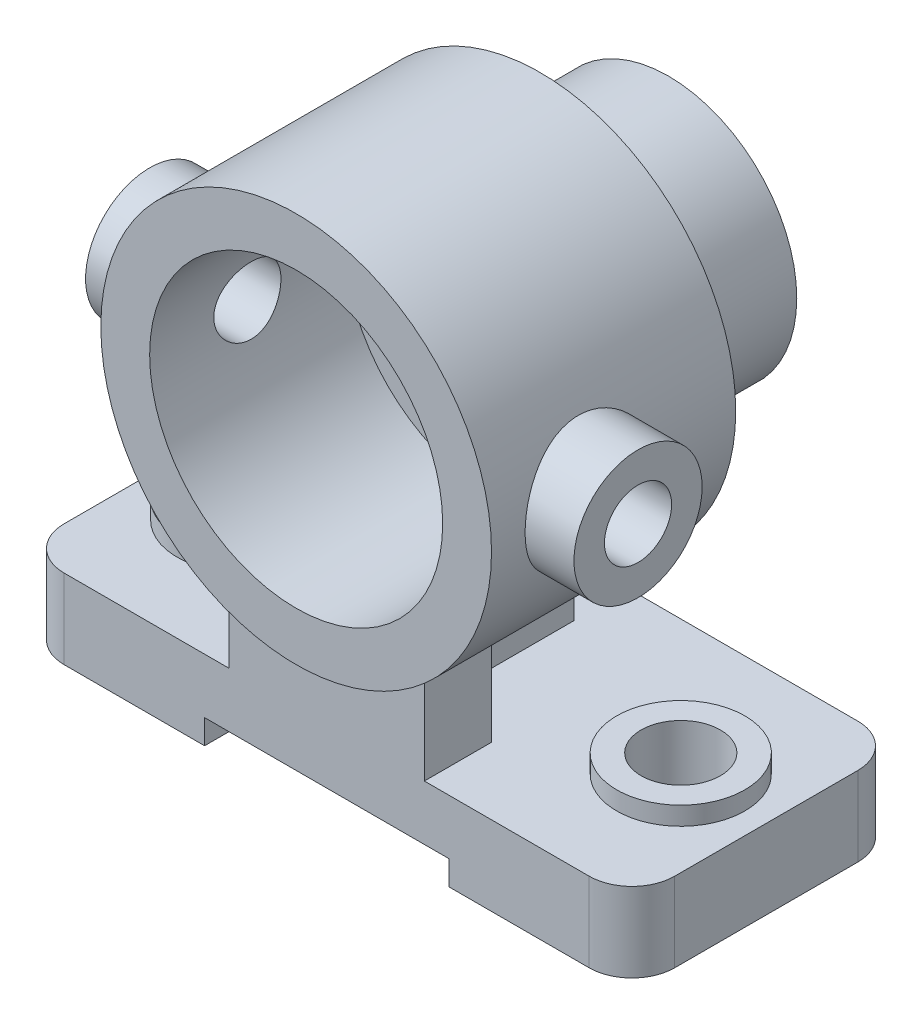
from build123d import *

# Parameters (mm, degrees)
EXTRUDE_1_DEPTH      = 13
SKETCH_2_R           = 10.5
EXTRUDE_2_DEPTH      = 3
EXTRUDE_3_DEPTH      = 56
SKETCH_4_R           = 32
EXTRUDE_4_DEPTH      = 5
EXTRUDE_4_DEPTH_BACK = 35
SKETCH_5_R           = 21
EXTRUDE_5_DEPTH      = 21
SKETCH_6_R           = 10.5
EXTRUDE_6_DEPTH      = 40
SKETCH_7_R           = 5.5
CUT_EXTRUDE_1_DEPTH  = 91
SKETCH_8_R           = 24
CUT_EXTRUDE_2_DEPTH  = 32
SKETCH_9_R           = 12
CUT_EXTRUDE_3_DEPTH  = 21
SKETCH_10_R          = 6.5
CUT_EXTRUDE_4_DEPTH  = 17
SKETCH_11_W          = 40
SKETCH_11_H          = 8
CUT_EXTRUDE_5_DEPTH  = 57


with BuildPart() as part:
    # 草图1 → 凸台-拉伸1 (new body)
    with BuildSketch(Plane(origin=(0, 0, 0), x_dir=(1, 0, 0), z_dir=(0, 1, 0))):
        with BuildLine():
            Line((-43, -22), (43, -22))
            ThreePointArc((43, -22), (47.949747468, -19.949747468), (50, -15))
            Line((50, -15), (50, 15))
            ThreePointArc((50, 15), (47.949747468, 19.949747468), (43, 22))
            Line((43, 22), (-43, 22))
            ThreePointArc((-43, 22), (-47.949747468, 19.949747468), (-50, 15))
            Line((-50, 15), (-50, -15))
            ThreePointArc((-50, -15), (-47.949747468, -19.949747468), (-43, -22))
        make_face()
    extrude(amount=EXTRUDE_1_DEPTH)

    # 草图2 → 凸台-拉伸2 (add)
    with BuildSketch(Plane(origin=(0, 13, 0), x_dir=(1, 0, 0), z_dir=(0, 1, 0))):
        with Locations((-36, 0)):
            Circle(SKETCH_2_R)
        with Locations((36, 0)):
            Circle(SKETCH_2_R)
    extrude(amount=EXTRUDE_2_DEPTH)

    # 草图3 → 凸台-拉伸3 (add)
    with BuildSketch(Plane(origin=(0, 13, 0), x_dir=(1, 0, 0), z_dir=(0, 1, 0))):
        Polygon((16, -22), (-16, -22), (-16, -11), (-5.5, -11), (-5.5, 13), (5.5, 13), (5.5, -11), (16, -11), align=None)
    extrude(amount=EXTRUDE_3_DEPTH)

    # 草图4 → 凸台-拉伸4 (add, two sides)
    with BuildSketch(Plane.XY.offset(22)) as extrude_4_sk:
        with Locations((0, 56)):
            Circle(SKETCH_4_R)
    extrude(amount=EXTRUDE_4_DEPTH)
    extrude(extrude_4_sk.sketch, amount=-EXTRUDE_4_DEPTH_BACK)

    # 草图5 → 凸台-拉伸5 (add)
    with BuildSketch(Plane(origin=(0, 0, -13), x_dir=(-1, 0, 0), z_dir=(0, 0, -1))):
        with Locations((0, 56)):
            Circle(SKETCH_5_R)
    extrude(amount=EXTRUDE_5_DEPTH)

    # 草图6 → 凸台-拉伸6 (add)
    with BuildSketch(Plane(origin=(0, 0, 0), x_dir=(0, 0, -1), z_dir=(1, 0, 0))):
        with Locations((-11, 56)):
            Circle(SKETCH_6_R)
    extrude_6 = extrude(amount=EXTRUDE_6_DEPTH)

    # 镜向1: 凸台-拉伸6 across plane
    add(extrude_6.mirror(Plane(origin=(0, 0, 0), x_dir=(0, 0, 1), z_dir=(1, 0, 0))))

    # 草图7 → 切除-拉伸1 (cut, through all)
    with BuildSketch(Plane.ZY.offset(40)):
        with Locations((11, 56)):
            Circle(SKETCH_7_R)
    extrude(amount=-CUT_EXTRUDE_1_DEPTH, mode=Mode.SUBTRACT)

    # 草图8 → 切除-拉伸2 (cut)
    with BuildSketch(Plane.XY.offset(27)):
        with Locations((0, 56)):
            Circle(SKETCH_8_R)
    extrude(amount=-CUT_EXTRUDE_2_DEPTH, mode=Mode.SUBTRACT)

    # 草图9 → 切除-拉伸3 (cut)
    with BuildSketch(Plane.XY.offset(-5)):
        with Locations((0, 56)):
            Circle(SKETCH_9_R)
    extrude(amount=-CUT_EXTRUDE_3_DEPTH, mode=Mode.SUBTRACT)

    # 草图10 → 切除-拉伸4 (cut, through all)
    with BuildSketch(Plane(origin=(0, 16, 0), x_dir=(1, 0, 0), z_dir=(0, 1, 0))):
        with Locations((-36, 0)):
            Circle(SKETCH_10_R)
        with Locations((36, 0)):
            Circle(SKETCH_10_R)
    extrude(amount=-CUT_EXTRUDE_4_DEPTH, mode=Mode.SUBTRACT)

    # 草图11 → 切除-拉伸5 (cut, through all)
    with BuildSketch(Plane.XY.offset(22)):
        Rectangle(SKETCH_11_W, SKETCH_11_H)
    extrude(amount=-CUT_EXTRUDE_5_DEPTH, mode=Mode.SUBTRACT)


solid = part.part
